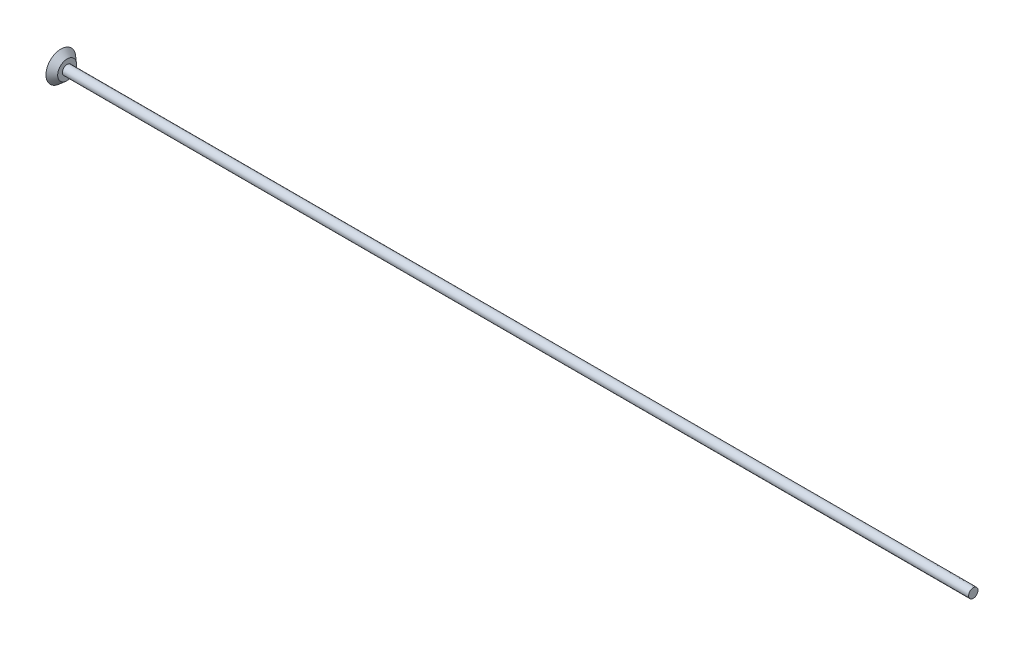
from build123d import *


with BuildPart() as part:
    # Sketch1 → Revolve1 (revolve)
    with BuildSketch(Plane(origin=(0, 0, 0), x_dir=(1, 0, 0), z_dir=(0, 1, 0))):
        Polygon((0, 0), (0, 4.7625), (2, 3.013628147), (2, 1.5), (292.030686223, 1.5), (292.030686223, 0), align=None)
    revolve(axis=Axis((292.030686223, 0, 0), (-1, 0, 0)))


solid = part.part
